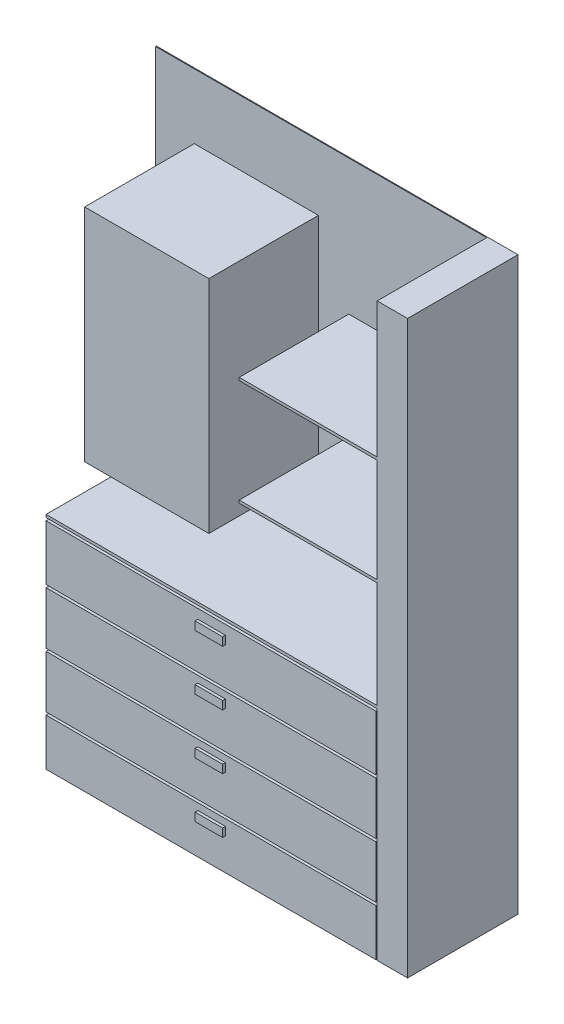
from build123d import *

# Parameters (mm, degrees)
SKETCH1_W           = 1310
SKETCH1_H           = 2070
BOSS_EXTRUDE1_DEPTH = 400
SKETCH2_W           = 1200
SKETCH2_H           = 400
CUT_EXTRUDE2_DEPTH  = 397
SKETCH5_W           = 1200
SKETCH5_H           = 10
CUT_EXTRUDE5_DEPTH  = 397
SKETCH6_W           = 1200
SKETCH6_H           = 10
CUT_EXTRUDE6_DEPTH  = 397
LPATTERN2_COUNT     = 3
LPATTERN2_PITCH     = 200
SKETCH9_W           = 100
SKETCH9_H           = 30
BOSS_EXTRUDE2_DEPTH = 10
LPATTERN3_COUNT     = 4
LPATTERN3_PITCH     = 200
SKETCH11_W          = 110
SKETCH11_H          = 2070
BOSS_EXTRUDE3_DEPTH = 400
SKETCH12_W          = 500
SKETCH12_H          = 10
CUT_EXTRUDE9_DEPTH  = 397
SKETCH13_W          = 1200
SKETCH13_H          = 870
CUT_EXTRUDE10_DEPTH = 397
SKETCH14_W          = 500
SKETCH14_H          = 10
BOSS_EXTRUDE4_DEPTH = 397
LPATTERN4_COUNT     = 2
LPATTERN4_PITCH     = 385
SKETCH16_W          = 5
SKETCH16_H          = 780
CUT_EXTRUDE11_DEPTH = 397
SKETCH17_W          = 450
SKETCH17_H          = 800
BOSS_EXTRUDE5_DEPTH = 397


with BuildPart() as part:
    # Sketch1 → Boss-Extrude1 (new body)
    with BuildSketch(Plane.XY):
        Rectangle(SKETCH1_W, SKETCH1_H)
    extrude(amount=BOSS_EXTRUDE1_DEPTH)

    # Sketch2 → Cut-Extrude2 (cut)
    with BuildSketch(Plane.XY.offset(400)):
        with Locations((-55, -35)):
            Rectangle(SKETCH2_W, SKETCH2_H)
    extrude(amount=-CUT_EXTRUDE2_DEPTH, mode=Mode.SUBTRACT)

    # Sketch5 → Cut-Extrude5 (cut)
    with BuildSketch(Plane.XY.offset(400)):
        with Locations((-55, -250)):
            Rectangle(SKETCH5_W, SKETCH5_H)
    extrude(amount=-CUT_EXTRUDE5_DEPTH, mode=Mode.SUBTRACT)

    # Sketch6 → Cut-Extrude6 (cut)
    with BuildSketch(Plane.XY.offset(400)):
        with Locations((-55, -460)):
            Rectangle(SKETCH6_W, SKETCH6_H)
    cut_extrude6 = extrude(amount=-CUT_EXTRUDE6_DEPTH, mode=Mode.SUBTRACT)

    # LPattern2: Cut-Extrude6 ×3
    with Locations(*[(0, -i * LPATTERN2_PITCH, 0) for i in range(1, LPATTERN2_COUNT)]):
        add(cut_extrude6, mode=Mode.SUBTRACT)

    # Sketch9 → Boss-Extrude2 (add)
    with BuildSketch(Plane.XY.offset(400)):
        with Locations((-55, -304.237135846)):
            Rectangle(SKETCH9_W, SKETCH9_H)
    boss_extrude2 = extrude(amount=BOSS_EXTRUDE2_DEPTH)

    # LPattern3: Boss-Extrude2 ×4
    with Locations(*[(0, -i * LPATTERN3_PITCH, 0) for i in range(1, LPATTERN3_COUNT)]):
        add(boss_extrude2)

    # Sketch12 → Cut-Extrude9 (cut)
    with BuildSketch(Plane.XY.offset(400)):
        with Locations((295, 670)):
            Rectangle(SKETCH12_W, SKETCH12_H)
    extrude(amount=-CUT_EXTRUDE9_DEPTH, mode=Mode.SUBTRACT)

    # Sketch13 → Cut-Extrude10 (cut)
    with BuildSketch(Plane.XY.offset(400)):
        with Locations((-55, 600)):
            Rectangle(SKETCH13_W, SKETCH13_H)
    extrude(amount=-CUT_EXTRUDE10_DEPTH, mode=Mode.SUBTRACT)



with BuildPart() as body_2:
    # Sketch11 → Boss-Extrude3 (new body)
    with BuildSketch(Plane.XY.offset(400)):
        with Locations((600, 0)):
            Rectangle(SKETCH11_W, SKETCH11_H)
    extrude(amount=-BOSS_EXTRUDE3_DEPTH)


with BuildPart() as part_1:
    add(part.part)

    add(body_2.part)  # Boss-Extrude4 merges body 2
    # Sketch14 → Boss-Extrude4 (add)
    with BuildSketch(Plane.XY.offset(3)):
        with Locations((295, 155)):
            Rectangle(SKETCH14_W, SKETCH14_H)
    boss_extrude4 = extrude(amount=BOSS_EXTRUDE4_DEPTH)

    # LPattern4: Boss-Extrude4 ×2
    with Locations(*[(0, i * LPATTERN4_PITCH, 0) for i in range(1, LPATTERN4_COUNT)]):
        add(boss_extrude4)

    # Sketch16 → Cut-Extrude11 (cut)
    with BuildSketch(Plane.XY.offset(400)):
        with Locations((542.5, -645)):
            Rectangle(SKETCH16_W, SKETCH16_H)
    extrude(amount=-CUT_EXTRUDE11_DEPTH, mode=Mode.SUBTRACT)

    # Sketch17 → Boss-Extrude5 (add)
    with BuildSketch(Plane.XY.offset(3)):
        with Locations((-290, 400)):
            Rectangle(SKETCH17_W, SKETCH17_H)
    extrude(amount=BOSS_EXTRUDE5_DEPTH)


solid = part_1.part
